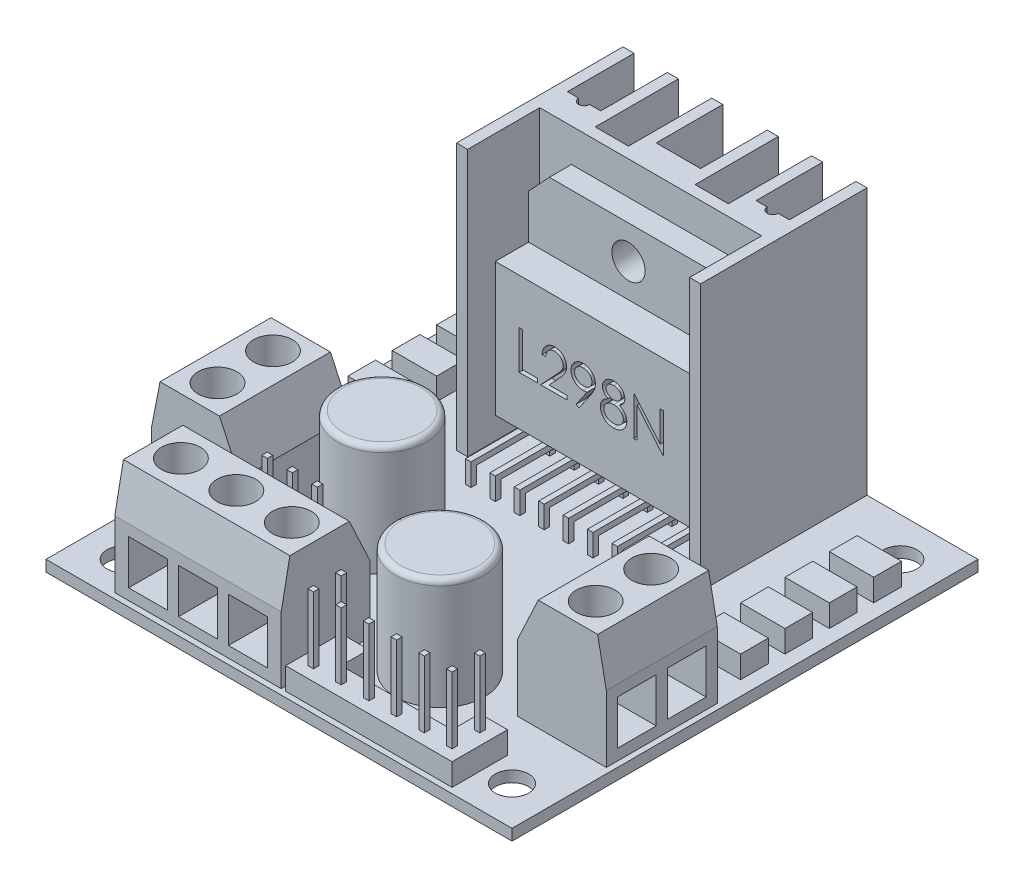
from build123d import *

# Parameters (mm, degrees)
BASE_SKETCH_W             = 42
BASE_SKETCH_H             = 42
BASE_SKETCH_R             = 1.5
BASE_DEPTH                = 1
RADIATOR_DEPTH            = 24
TERMINAL_1_SKETCH_W       = 8
TERMINAL_1_SKETCH_H       = 10
TERMINAL_1_DEPTH          = 10
TERMINAL_2_SKETCH_W       = 15
TERMINAL_2_SKETCH_H       = 8
TERMINAL_2_DEPTH          = 10
CHAMFER_25_SIZE2          = 1.865230633
CHAMFER_25_SIZE           = 4
CHAMFER_10_SIZE           = 4
CHAMFER_10_SIZE2          = 0.777521237
CHAMFER_10_PART_2_SIZE    = 4
CHAMFER_10_PART_2_SIZE2   = 0.777521237
CHAMFER_10_PART_3_SIZE    = 4
CHAMFER_10_PART_3_SIZE2   = 0.777521237
DIODE_SKETCH_W            = 4
DIODE_SKETCH_H            = 2.5
DIODE_DEPTH               = 2
CAPACITOR_SKETCH_R        = 4
CAPACITOR_DEPTH           = 10
FILLET_2_R                = 0.5
RAIL_6_DEPTH              = 2
RAIL_3_SKETCH_W           = 6.6
RAIL_3_SKETCH_H           = 2.2
RAIL_3_DEPTH              = 2
JACK_6_SKETCH_W           = 0.5
JACK_6_SKETCH_H           = 0.5
JACK_6_DEPTH              = 6
JACK_3_SKETCH_W           = 0.5
JACK_3_SKETCH_H           = 0.5
JACK_3_DEPTH              = 6
L298_IC_DEPTH             = 5
L298_CUT_SKETCH_W         = 18
L298_CUT_SKETCH_H         = 6
L298_CUT_DEPTH            = 3
L298_LEG_1_SKETCH_W       = 0.5
L298_LEG_1_SKETCH_H       = 0.5
L298_LEG_1_DEPTH          = 1.5
L298_LEG_2_SKETCH_W       = 0.5
L298_LEG_2_SKETCH_H       = 0.5
L298_LEG_2_DEPTH          = 6
L298_LEG_3_SKETCH_W       = 0.5
L298_LEG_3_SKETCH_H       = 0.5
L298_LEG_3_DEPTH          = 2.5
BOSS_EXTRUDE1_REACH       = 26
SKETCH1_W                 = 0.5
SKETCH1_H                 = 0.5
L298_NAME_DEPTH           = 1
ROLE_SKETCH_R             = 1.5
ROLE_DEPTH                = 11.5
ROLE_TERMINAL_1A_SKETCH_W = 3.5
ROLE_TERMINAL_1A_SKETCH_H = 4
ROLE_TERMINAL_1A_DEPTH    = 4
ROLE_TERMINAL_1B_SKETCH_W = 3.5
ROLE_TERMINAL_1B_SKETCH_H = 4
ROLE_TERMINAL_1B_DEPTH    = 3.5
ROLE_TERMINAL_2_SKETCH_W  = 3.5
ROLE_TERMINAL_2_SKETCH_H  = 4
ROLE_TERMINAL_2_DEPTH     = 3.5
SKETCH4_R                 = 1.75
ROLE_TERMINAL_3_DEPTH     = 3.5


with BuildPart() as part:
    # base_sketch → base (new body)
    with BuildSketch(Plane(origin=(0, 0, 0), x_dir=(1, 0, 0), z_dir=(0, 1, 0))):
        with Locations((-21, -21)):
            Rectangle(BASE_SKETCH_W, BASE_SKETCH_H)
        with Locations((-38.5, -3.5)):
            Circle(BASE_SKETCH_R, mode=Mode.SUBTRACT)
        with Locations((-3.5, -3.5)):
            Circle(BASE_SKETCH_R, mode=Mode.SUBTRACT)
        with Locations((-38.5, -38.5)):
            Circle(BASE_SKETCH_R, mode=Mode.SUBTRACT)
        with Locations((-3.5, -38.5)):
            Circle(BASE_SKETCH_R, mode=Mode.SUBTRACT)
    extrude(amount=BASE_DEPTH)

    # radiator_sketch → radiator (add)
    with BuildSketch(Plane(origin=(0, 1, 0), x_dir=(-1, 0, 0), z_dir=(0, 1, 0))):
        with BuildLine():
            Line((10, 0), (10, 15))
            Line((10, 15), (11, 15))
            Line((11, 15), (11, 8.5))
            Line((11, 8.5), (31, 8.5))
            Line((31, 8.5), (31, 15))
            Line((31, 15), (32, 15))
            Line((32, 15), (32, 0))
            Line((32, 0), (31, 0))
            Line((31, 0), (31, 6))
            Line((31, 6), (30, 6))
            ThreePointArc((30, 6), (29.5, 6.5), (29, 6))
            Line((29, 6), (28, 6))
            Line((28, 6), (28, 0))
            Line((28, 0), (27, 0))
            Line((27, 0), (27, 7.5))
            Line((27, 7.5), (24, 7.5))
            Line((24, 7.5), (24, 0))
            Line((24, 0), (23, 0))
            Line((23, 0), (23, 6))
            Line((23, 6), (19, 6))
            Line((19, 6), (19, 0))
            Line((19, 0), (18, 0))
            Line((18, 0), (18, 7.5))
            Line((18, 7.5), (15, 7.5))
            Line((15, 7.5), (15, 0))
            Line((15, 0), (14, 0))
            Line((14, 0), (14, 6))
            Line((14, 6), (13, 6))
            ThreePointArc((13, 6), (12.5, 6.5), (12, 6))
            Line((12, 6), (11, 6))
            Line((11, 6), (11, 0))
            Line((11, 0), (10, 0))
        make_face()
    extrude(amount=RADIATOR_DEPTH)

    # terminal_1_sketch → terminal_1 (add)
    with BuildSketch(Plane(origin=(0, 1, 0), x_dir=(-1, 0, 0), z_dir=(0, 1, 0))):
        with Locations((4.5, 28)):
            Rectangle(TERMINAL_1_SKETCH_W, TERMINAL_1_SKETCH_H)
        with Locations((37.5, 28)):
            Rectangle(TERMINAL_1_SKETCH_W, TERMINAL_1_SKETCH_H)
    extrude(amount=TERMINAL_1_DEPTH)

    # terminal_2_sketch → terminal_2 (add)
    with BuildSketch(Plane(origin=(0, 1, 0), x_dir=(-1, 0, 0), z_dir=(0, 1, 0))):
        with Locations((28.8, 37.5)):
            Rectangle(TERMINAL_2_SKETCH_W, TERMINAL_2_SKETCH_H)
    extrude(amount=TERMINAL_2_DEPTH)

    # chamfer_25
    chamfer_25_edges = [part.edges().sort_by_distance(p)[0] for p in [
        (-33.5, 11, 28),
        (-8.5, 11, 28),
        (-28.8, 11, 33.5),
    ]]
    chamfer(chamfer_25_edges, length=CHAMFER_25_SIZE, length2=CHAMFER_25_SIZE2)

    # chamfer_10
    chamfer_10_edges = [part.edges().sort_by_distance(p)[0] for p in [
        (-41.5, 11, 28),
    ]]
    chamfer_10_side = [part.faces().sort_by_distance(p)[0] for p in [
        (-41.5, 6, 28),
    ]]
    chamfer(chamfer_10_edges, length=CHAMFER_10_SIZE, length2=CHAMFER_10_SIZE2, reference=chamfer_10_side[0])

    # chamfer_10 part 2
    chamfer_10_part_2_edges = [part.edges().sort_by_distance(p)[0] for p in [
        (-0.5, 11, 28),
    ]]
    chamfer_10_part_2_side = [part.faces().sort_by_distance(p)[0] for p in [
        (-0.5, 6, 28),
    ]]
    chamfer(chamfer_10_part_2_edges, length=CHAMFER_10_PART_2_SIZE, length2=CHAMFER_10_PART_2_SIZE2, reference=chamfer_10_part_2_side[0])

    # chamfer_10 part 3
    chamfer_10_part_3_edges = [part.edges().sort_by_distance(p)[0] for p in [
        (-28.8, 11, 41.5),
    ]]
    chamfer_10_part_3_side = [part.faces().sort_by_distance(p)[0] for p in [
        (-28.8, 6, 41.5),
    ]]
    chamfer(chamfer_10_part_3_edges, length=CHAMFER_10_PART_3_SIZE, length2=CHAMFER_10_PART_3_SIZE2, reference=chamfer_10_part_3_side[0])

    # diode_sketch → diode (add)
    with BuildSketch(Plane(origin=(0, 1, 0), x_dir=(-1, 0, 0), z_dir=(0, 1, 0))):
        with Locations((3.3, 10.85)):
            Rectangle(DIODE_SKETCH_W, DIODE_SKETCH_H)
        with Locations((3.3, 6.85)):
            Rectangle(DIODE_SKETCH_W, DIODE_SKETCH_H)
        with Locations((3.3, 14.85)):
            Rectangle(DIODE_SKETCH_W, DIODE_SKETCH_H)
        with Locations((3.3, 18.85)):
            Rectangle(DIODE_SKETCH_W, DIODE_SKETCH_H)
        with Locations((38.7, 18.85)):
            Rectangle(DIODE_SKETCH_W, DIODE_SKETCH_H)
        with Locations((38.7, 14.85)):
            Rectangle(DIODE_SKETCH_W, DIODE_SKETCH_H)
        with Locations((38.7, 10.85)):
            Rectangle(DIODE_SKETCH_W, DIODE_SKETCH_H)
        with Locations((38.7, 6.85)):
            Rectangle(DIODE_SKETCH_W, DIODE_SKETCH_H)
    extrude(amount=DIODE_DEPTH)

    # capacitor_sketch → capacitor (add)
    with BuildSketch(Plane(origin=(0, 1, 0), x_dir=(-1, 0, 0), z_dir=(0, 1, 0))):
        with Locations((28.5, 25.2)):
            Circle(CAPACITOR_SKETCH_R)
        with Locations((15.5, 33)):
            Circle(CAPACITOR_SKETCH_R)
    extrude(amount=CAPACITOR_DEPTH)

    # fillet 2
    fillet_2_edges = [part.edges().sort_by_distance(p)[0] for p in [
        (-24.5, 11, 25.2),
        (-11.5, 11, 33),
    ]]
    fillet(fillet_2_edges, radius=FILLET_2_R)

    # rail_6_sketch → rail_6 (add)
    with BuildSketch(Plane(origin=(0, 1, 0), x_dir=(-1, 0, 0), z_dir=(0, 1, 0))):
        Polygon((20.9, 41.5), (5.9, 41.5), (5.9, 36.5), (8.4, 36.5), (8.4, 39), (18.4, 39), (18.4, 36.5), (20.9, 36.5), align=None)
    extrude(amount=RAIL_6_DEPTH)

    # rail_3_sketch → rail_3 (add)
    with BuildSketch(Plane(origin=(0, 1, 0), x_dir=(-1, 0, 0), z_dir=(0, 1, 0))):
        with Locations((29.9, 31.9)):
            Rectangle(RAIL_3_SKETCH_W, RAIL_3_SKETCH_H)
    extrude(amount=RAIL_3_DEPTH)

    # jack_6_sketch → jack_6 (add)
    with BuildSketch(Plane(origin=(0, 3, 0), x_dir=(-1, 0, 0), z_dir=(0, 1, 0))):
        with Locations((17.15, 40.25)):
            Rectangle(JACK_6_SKETCH_W, JACK_6_SKETCH_H)
        with Locations((19.65, 40.25)):
            Rectangle(JACK_6_SKETCH_W, JACK_6_SKETCH_H)
        with Locations((14.65, 40.25)):
            Rectangle(JACK_6_SKETCH_W, JACK_6_SKETCH_H)
        with Locations((12.15, 40.25)):
            Rectangle(JACK_6_SKETCH_W, JACK_6_SKETCH_H)
        with Locations((9.65, 40.25)):
            Rectangle(JACK_6_SKETCH_W, JACK_6_SKETCH_H)
        with Locations((7.15, 40.25)):
            Rectangle(JACK_6_SKETCH_W, JACK_6_SKETCH_H)
        with Locations((19.65, 37.75)):
            Rectangle(JACK_6_SKETCH_W, JACK_6_SKETCH_H)
        with Locations((7.15, 37.75)):
            Rectangle(JACK_6_SKETCH_W, JACK_6_SKETCH_H)
    extrude(amount=JACK_6_DEPTH)

    # jack_3_sketch → jack_3 (add)
    with BuildSketch(Plane(origin=(0, 3, 0), x_dir=(1, 0, 0), z_dir=(0, 1, 0))):
        with Locations((-29.9, -31.9)):
            Rectangle(JACK_3_SKETCH_W, JACK_3_SKETCH_H)
        with Locations((-32.15, -31.9)):
            Rectangle(JACK_3_SKETCH_W, JACK_3_SKETCH_H)
        with Locations((-27.65, -31.9)):
            Rectangle(JACK_3_SKETCH_W, JACK_3_SKETCH_H)
    extrude(amount=JACK_3_DEPTH)

    # L298_sketch → L298_IC (add)
    with BuildSketch(Plane.XY.offset(8.5)):
        Polygon((-30, 19.987466442), (-30, 4), (-12, 4), (-12, 19.987466442), (-13.862533558, 22), (-28.137466442, 22), align=None)
    extrude(amount=L298_IC_DEPTH)

    # L298_cut_sketch → L298_cut (cut)
    with BuildSketch(Plane.XY.offset(13.5)):
        with Locations((-21, 19)):
            Rectangle(L298_CUT_SKETCH_W, L298_CUT_SKETCH_H)
    extrude(amount=-L298_CUT_DEPTH, mode=Mode.SUBTRACT)

    # L298_leg_1_sketch → L298_leg_1 (add)
    with BuildSketch(Plane.XZ.offset(-4)):
        with Locations((-27.6, 11)):
            Rectangle(L298_LEG_1_SKETCH_W, L298_LEG_1_SKETCH_H)
        with Locations((-28.7, 11)):
            Rectangle(L298_LEG_1_SKETCH_W, L298_LEG_1_SKETCH_H)
        with Locations((-26.5, 11)):
            Rectangle(L298_LEG_1_SKETCH_W, L298_LEG_1_SKETCH_H)
        with Locations((-25.4, 11)):
            Rectangle(L298_LEG_1_SKETCH_W, L298_LEG_1_SKETCH_H)
        with Locations((-24.3, 11)):
            Rectangle(L298_LEG_1_SKETCH_W, L298_LEG_1_SKETCH_H)
        with Locations((-23.2, 11)):
            Rectangle(L298_LEG_1_SKETCH_W, L298_LEG_1_SKETCH_H)
        with Locations((-22.1, 11)):
            Rectangle(L298_LEG_1_SKETCH_W, L298_LEG_1_SKETCH_H)
        with Locations((-21, 11)):
            Rectangle(L298_LEG_1_SKETCH_W, L298_LEG_1_SKETCH_H)
        with Locations((-19.9, 11)):
            Rectangle(L298_LEG_1_SKETCH_W, L298_LEG_1_SKETCH_H)
        with Locations((-18.8, 11)):
            Rectangle(L298_LEG_1_SKETCH_W, L298_LEG_1_SKETCH_H)
        with Locations((-17.7, 11)):
            Rectangle(L298_LEG_1_SKETCH_W, L298_LEG_1_SKETCH_H)
        with Locations((-16.6, 11)):
            Rectangle(L298_LEG_1_SKETCH_W, L298_LEG_1_SKETCH_H)
        with Locations((-15.5, 11)):
            Rectangle(L298_LEG_1_SKETCH_W, L298_LEG_1_SKETCH_H)
        with Locations((-14.4, 11)):
            Rectangle(L298_LEG_1_SKETCH_W, L298_LEG_1_SKETCH_H)
        with Locations((-13.3, 11)):
            Rectangle(L298_LEG_1_SKETCH_W, L298_LEG_1_SKETCH_H)
    extrude(amount=L298_LEG_1_DEPTH)

    # L298_leg_2_sketch → L298_leg_2 (add)
    with BuildSketch(Plane.XY.offset(11.25)):
        with Locations((-13.3, 2.75)):
            Rectangle(L298_LEG_2_SKETCH_W, L298_LEG_2_SKETCH_H)
        with Locations((-15.5, 2.75)):
            Rectangle(L298_LEG_2_SKETCH_W, L298_LEG_2_SKETCH_H)
        with Locations((-17.7, 2.75)):
            Rectangle(L298_LEG_2_SKETCH_W, L298_LEG_2_SKETCH_H)
        with Locations((-19.9, 2.75)):
            Rectangle(L298_LEG_2_SKETCH_W, L298_LEG_2_SKETCH_H)
        with Locations((-22.1, 2.75)):
            Rectangle(L298_LEG_2_SKETCH_W, L298_LEG_2_SKETCH_H)
        with Locations((-24.3, 2.75)):
            Rectangle(L298_LEG_2_SKETCH_W, L298_LEG_2_SKETCH_H)
        with Locations((-26.5, 2.75)):
            Rectangle(L298_LEG_2_SKETCH_W, L298_LEG_2_SKETCH_H)
        with Locations((-28.7, 2.75)):
            Rectangle(L298_LEG_2_SKETCH_W, L298_LEG_2_SKETCH_H)
    extrude(amount=L298_LEG_2_DEPTH)

    # L298_leg_3_sketch → L298_leg_3 (add)
    with BuildSketch(Plane.XZ):
        with Locations((-28.7, 17)):
            Rectangle(L298_LEG_3_SKETCH_W, L298_LEG_3_SKETCH_H)
        with Locations((-26.5, 17)):
            Rectangle(L298_LEG_3_SKETCH_W, L298_LEG_3_SKETCH_H)
        with Locations((-24.3, 17)):
            Rectangle(L298_LEG_3_SKETCH_W, L298_LEG_3_SKETCH_H)
        with Locations((-22.1, 17)):
            Rectangle(L298_LEG_3_SKETCH_W, L298_LEG_3_SKETCH_H)
        with Locations((-19.9, 17)):
            Rectangle(L298_LEG_3_SKETCH_W, L298_LEG_3_SKETCH_H)
        with Locations((-17.7, 17)):
            Rectangle(L298_LEG_3_SKETCH_W, L298_LEG_3_SKETCH_H)
        with Locations((-15.5, 17)):
            Rectangle(L298_LEG_3_SKETCH_W, L298_LEG_3_SKETCH_H)
        with Locations((-13.3, 17)):
            Rectangle(L298_LEG_3_SKETCH_W, L298_LEG_3_SKETCH_H)
    extrude(amount=-L298_LEG_3_DEPTH)

    # Sketch1 → Boss-Extrude1 (add, up to next)
    with BuildSketch(Plane(origin=(0, 1, 0), x_dir=(1, 0, 0), z_dir=(0, 1, 0)), mode=Mode.PRIVATE) as boss_extrude1_sk1:
        with Locations((-14.4, -11)):
            Rectangle(SKETCH1_W, SKETCH1_H)
    boss_extrude1_tool1 = extrude(boss_extrude1_sk1.sketch, amount=BOSS_EXTRUDE1_REACH, mode=Mode.PRIVATE) - part.part
    add(boss_extrude1_tool1.solids().sort_by_distance((-14.4, 1, 11))[0])
    # Sketch1 → Boss-Extrude1 (add, up to next)
    with BuildSketch(Plane(origin=(0, 1, 0), x_dir=(1, 0, 0), z_dir=(0, 1, 0)), mode=Mode.PRIVATE) as boss_extrude1_sk2:
        with Locations((-16.6, -11)):
            Rectangle(SKETCH1_W, SKETCH1_H)
    boss_extrude1_tool2 = extrude(boss_extrude1_sk2.sketch, amount=BOSS_EXTRUDE1_REACH, mode=Mode.PRIVATE) - part.part
    add(boss_extrude1_tool2.solids().sort_by_distance((-16.6, 1, 11))[0])
    # Sketch1 → Boss-Extrude1 (add, up to next)
    with BuildSketch(Plane(origin=(0, 1, 0), x_dir=(1, 0, 0), z_dir=(0, 1, 0)), mode=Mode.PRIVATE) as boss_extrude1_sk3:
        with Locations((-18.8, -11)):
            Rectangle(SKETCH1_W, SKETCH1_H)
    boss_extrude1_tool3 = extrude(boss_extrude1_sk3.sketch, amount=BOSS_EXTRUDE1_REACH, mode=Mode.PRIVATE) - part.part
    add(boss_extrude1_tool3.solids().sort_by_distance((-18.8, 1, 11))[0])
    # Sketch1 → Boss-Extrude1 (add, up to next)
    with BuildSketch(Plane(origin=(0, 1, 0), x_dir=(1, 0, 0), z_dir=(0, 1, 0)), mode=Mode.PRIVATE) as boss_extrude1_sk4:
        with Locations((-21, -11)):
            Rectangle(SKETCH1_W, SKETCH1_H)
    boss_extrude1_tool4 = extrude(boss_extrude1_sk4.sketch, amount=BOSS_EXTRUDE1_REACH, mode=Mode.PRIVATE) - part.part
    add(boss_extrude1_tool4.solids().sort_by_distance((-21, 1, 11))[0])
    # Sketch1 → Boss-Extrude1 (add, up to next)
    with BuildSketch(Plane(origin=(0, 1, 0), x_dir=(1, 0, 0), z_dir=(0, 1, 0)), mode=Mode.PRIVATE) as boss_extrude1_sk5:
        with Locations((-23.2, -11)):
            Rectangle(SKETCH1_W, SKETCH1_H)
    boss_extrude1_tool5 = extrude(boss_extrude1_sk5.sketch, amount=BOSS_EXTRUDE1_REACH, mode=Mode.PRIVATE) - part.part
    add(boss_extrude1_tool5.solids().sort_by_distance((-23.2, 1, 11))[0])
    # Sketch1 → Boss-Extrude1 (add, up to next)
    with BuildSketch(Plane(origin=(0, 1, 0), x_dir=(1, 0, 0), z_dir=(0, 1, 0)), mode=Mode.PRIVATE) as boss_extrude1_sk6:
        with Locations((-25.4, -11)):
            Rectangle(SKETCH1_W, SKETCH1_H)
    boss_extrude1_tool6 = extrude(boss_extrude1_sk6.sketch, amount=BOSS_EXTRUDE1_REACH, mode=Mode.PRIVATE) - part.part
    add(boss_extrude1_tool6.solids().sort_by_distance((-25.4, 1, 11))[0])
    # Sketch1 → Boss-Extrude1 (add, up to next)
    with BuildSketch(Plane(origin=(0, 1, 0), x_dir=(1, 0, 0), z_dir=(0, 1, 0)), mode=Mode.PRIVATE) as boss_extrude1_sk7:
        with Locations((-27.6, -11)):
            Rectangle(SKETCH1_W, SKETCH1_H)
    boss_extrude1_tool7 = extrude(boss_extrude1_sk7.sketch, amount=BOSS_EXTRUDE1_REACH, mode=Mode.PRIVATE) - part.part
    add(boss_extrude1_tool7.solids().sort_by_distance((-27.6, 1, 11))[0])

    # L298_name_sketch → L298_name (cut)
    with BuildSketch(Plane.XY.offset(13.5)):
        Polygon((-27.846931762, 11.915865738), (-27.532829198, 11.915865738), (-27.532829198, 8.774840097), (-26.186675351, 8.774840097), (-26.186675351, 8.415865738), (-27.846931762, 8.415865738), align=None)
        with BuildLine():
            Line((-25.468726633, 10.838942661), (-25.782829198, 10.838942661))
            add(Edge.make_bspline(
                [(-25.782829198, 10.838942661), (-25.780782045, 10.880613549), (-25.77676149, 10.962454063), (-25.757933201, 11.08177797), (-25.730992324, 11.195832768), (-25.69290087, 11.303702682), (-25.645594592, 11.40634149), (-25.588864565, 11.503341505), (-25.521670714, 11.594332694), (-25.44546398, 11.678471537), (-25.362695341, 11.755659108), (-25.273389402, 11.822314351), (-25.179544374, 11.878632022), (-25.081444976, 11.925713264), (-24.977984412, 11.96105311), (-24.870101554, 11.98727475), (-24.757322418, 12.003051095), (-24.680482396, 12.004746881), (-24.641402915, 12.005609328)],
                knots=[0, 0, 0, 0, 0.000125083, 0.00024566, 0.000361805, 0.000476223, 0.000588214, 0.000700404, 0.000812728, 0.00092691, 0.001040529, 0.001151727, 0.001260545, 0.001368429, 0.001477521, 0.001587884, 0.001701119, 0.00181831, 0.00181831, 0.00181831, 0.00181831], degree=3))
            add(Edge.make_bspline(
                [(-24.641402915, 12.005609328), (-24.603024841, 12.004710871), (-24.527613297, 12.002945436), (-24.417551282, 11.987784407), (-24.312773988, 11.964038815), (-24.213486221, 11.930723399), (-24.120480157, 11.885938972), (-24.033057112, 11.832141433), (-23.950176301, 11.769921602), (-23.875569518, 11.696667788), (-23.807061439, 11.618465404), (-23.747959183, 11.5349775), (-23.69734602, 11.448748214), (-23.65515834, 11.359120013), (-23.624102201, 11.265248985), (-23.600523993, 11.168501782), (-23.587196579, 11.067876971), (-23.585151156, 10.999770415), (-23.584111249, 10.965144584)],
                knots=[0, 0, 0, 0, 0.000115089, 0.000226145, 0.000332614, 0.000437044, 0.000539592, 0.000641561, 0.000744629, 0.00084975, 0.000954621, 0.001056175, 0.001156101, 0.001254284, 0.001352726, 0.001452208, 0.001552655, 0.001656537, 0.001656537, 0.001656537, 0.001656537], degree=3))
            add(Edge.make_bspline(
                [(-23.584111249, 10.965144584), (-23.585804512, 10.916396749), (-23.589161323, 10.819756536), (-23.6178757, 10.677741673), (-23.662722211, 10.540148254), (-23.716719568, 10.429410952), (-23.771192012, 10.340177458), (-23.820279519, 10.266708753), (-23.87774433, 10.187603285), (-23.944422828, 10.103125947), (-24.0189357, 10.012615042), (-24.101957864, 9.916125247), (-24.194081346, 9.814653477), (-24.258739846, 9.745347876), (-24.292244262, 9.709435449)],
                knots=[0, 0, 0, 0, 0.000146118, 0.000289672, 0.0004329, 0.00057934, 0.000657978, 0.000746456, 0.000844345, 0.000951219, 0.001069268, 0.00119604, 0.001333047, 0.001480391, 0.001480391, 0.001480391, 0.001480391], degree=3))
            Line((-24.292244262, 9.709435449), (-25.167945383, 8.774840097))
            Line((-25.167945383, 8.774840097), (-23.539239454, 8.774840097))
            Line((-23.539239454, 8.774840097), (-23.539239454, 8.415865738))
            Line((-23.539239454, 8.415865738), (-25.917444582, 8.415865738))
            Line((-25.917444582, 8.415865738), (-24.560072787, 9.864383366))
            add(Edge.make_bspline(
                [(-24.560072787, 9.864383366), (-24.5270249, 9.898881673), (-24.463546673, 9.965145859), (-24.373764097, 10.061888819), (-24.293125108, 10.15163836), (-24.221107715, 10.234224909), (-24.15927421, 10.310856476), (-24.104401978, 10.37905118), (-24.060436387, 10.44180563), (-24.012720991, 10.514546244), (-23.96650701, 10.603358561), (-23.926794654, 10.711892251), (-23.902579806, 10.823619503), (-23.89967497, 10.89912154), (-23.898213813, 10.937099712)],
                knots=[0, 0, 0, 0, 0.000143319, 0.000275286, 0.00039593, 0.000505287, 0.000603949, 0.000691331, 0.000767782, 0.00083371, 0.000952247, 0.001067137, 0.001179618, 0.001293462, 0.001293462, 0.001293462, 0.001293462], degree=3))
            add(Edge.make_bspline(
                [(-23.898213813, 10.937099712), (-23.898849555, 10.960981111), (-23.900102481, 11.008046761), (-23.911160179, 11.07705252), (-23.927870685, 11.143617334), (-23.951815943, 11.207945953), (-23.983422683, 11.269391605), (-24.021896063, 11.328029085), (-24.066286126, 11.38471805), (-24.117637396, 11.437871349), (-24.174048915, 11.486552554), (-24.233643165, 11.529676639), (-24.296693269, 11.56571575), (-24.362933391, 11.595259247), (-24.432178861, 11.618434629), (-24.504563606, 11.634493208), (-24.579887622, 11.644575692), (-24.631321118, 11.645939864), (-24.657528717, 11.646634969)],
                knots=[0, 0, 0, 0, 7.16e-05, 0.00014111, 0.00020913, 0.00027724, 0.000346538, 0.000415963, 0.000487357, 0.000562233, 0.000637292, 0.000710646, 0.000782564, 0.000854749, 0.000927915, 0.001001225, 0.001076884, 0.001155488, 0.001155488, 0.001155488, 0.001155488], degree=3))
            add(Edge.make_bspline(
                [(-24.657528717, 11.646634969), (-24.68489955, 11.645919936), (-24.738651346, 11.644515731), (-24.817570379, 11.634693067), (-24.892856156, 11.617747227), (-24.964698059, 11.594570552), (-25.033217645, 11.565112004), (-25.098081689, 11.528420259), (-25.159144578, 11.484636766), (-25.216521102, 11.434996209), (-25.269385081, 11.379728608), (-25.315831957, 11.318118645), (-25.356415971, 11.25129123), (-25.391825204, 11.179426679), (-25.420580894, 11.101872899), (-25.442554045, 11.018905194), (-25.459940891, 10.930883813), (-25.465749412, 10.870098728), (-25.468726633, 10.838942661)],
                knots=[0, 0, 0, 0, 8.2106e-05, 0.000161243, 0.000238127, 0.000313291, 0.000387401, 0.000461495, 0.000536397, 0.000612445, 0.000688819, 0.000765383, 0.000843422, 0.000923066, 0.001005373, 0.001091093, 0.001180334, 0.001274175, 0.001274175, 0.001274175, 0.001274175], degree=3))
        make_face()
        with BuildLine():
            Line((-22.462316377, 8.326122148), (-22.71331798, 8.500701475))
            Line((-22.71331798, 8.500701475), (-21.740160928, 9.923277597))
            add(Edge.make_bspline(
                [(-21.740160928, 9.923277597), (-21.802251664, 9.915684534), (-21.924511784, 9.900733369), (-22.047648886, 9.897986714), (-22.108249871, 9.896634969)],
                knots=[0, 0, 0, 0, 0.000187529, 0.000369255, 0.000369255, 0.000369255, 0.000369255], degree=3))
            add(Edge.make_bspline(
                [(-22.108249871, 9.896634969), (-22.144991918, 9.897576045), (-22.217113345, 9.899423296), (-22.323144998, 9.914065104), (-22.425030558, 9.936615232), (-22.522499914, 9.970263987), (-22.615919419, 10.012082196), (-22.705085133, 10.06393921), (-22.789877023, 10.124945501), (-22.869384433, 10.194778493), (-22.941696172, 10.271456545), (-23.00611947, 10.352612188), (-23.059660602, 10.439188159), (-23.104137187, 10.529418378), (-23.137867641, 10.624599729), (-23.162430178, 10.723649129), (-23.177552532, 10.827260771), (-23.179351628, 10.897785902), (-23.180265095, 10.933594103)],
                knots=[0, 0, 0, 0, 0.000110185, 0.000216284, 0.000320547, 0.000422759, 0.000525058, 0.000627155, 0.000731643, 0.000837964, 0.0009441, 0.00104747, 0.001148247, 0.001248901, 0.001348697, 0.001450555, 0.001554666, 0.00166205, 0.00166205, 0.00166205, 0.00166205], degree=3))
            add(Edge.make_bspline(
                [(-23.180265095, 10.933594103), (-23.17853066, 10.982562756), (-23.175126317, 11.078678288), (-23.147727799, 11.219112057), (-23.10266746, 11.3518986), (-23.039839083, 11.476688794), (-22.960704362, 11.591687533), (-22.865595772, 11.695296142), (-22.755091807, 11.786040996), (-22.631709788, 11.864045074), (-22.498356768, 11.926780071), (-22.358688109, 11.973019371), (-22.213773989, 12.000218119), (-22.115606319, 12.00380398), (-22.066182563, 12.005609328)],
                knots=[0, 0, 0, 0, 0.000146818, 0.000288173, 0.000427413, 0.000566316, 0.000705952, 0.000844895, 0.000986821, 0.001133677, 0.001281714, 0.001427825, 0.001574003, 0.00172222, 0.00172222, 0.00172222, 0.00172222], degree=3))
            add(Edge.make_bspline(
                [(-22.066182563, 12.005609328), (-22.017694143, 12.003779165), (-21.921885596, 12.000162935), (-21.78099659, 11.973678966), (-21.646055573, 11.929042293), (-21.517810586, 11.867357729), (-21.399071174, 11.790036822), (-21.292295363, 11.697902298), (-21.199919824, 11.590896771), (-21.122095943, 11.471608281), (-21.059625903, 11.343441299), (-21.01455362, 11.209657377), (-20.986807981, 11.071218656), (-20.983311654, 10.977424181), (-20.981547146, 10.930088494)],
                knots=[0, 0, 0, 0, 0.000145418, 0.000287333, 0.000428343, 0.000570713, 0.000713061, 0.00085223, 0.000992387, 0.001135706, 0.001278381, 0.001418948, 0.001558239, 0.001700158, 0.001700158, 0.001700158, 0.001700158], degree=3))
            add(Edge.make_bspline(
                [(-20.981547146, 10.930088494), (-20.982725555, 10.893344727), (-20.985115663, 10.818819186), (-21.00185197, 10.705588844), (-21.030272155, 10.590137614), (-21.062523854, 10.492416018), (-21.093656022, 10.411707569), (-21.122957153, 10.347955989), (-21.155469307, 10.280854725), (-21.193388072, 10.211107387), (-21.234150369, 10.137824852), (-21.280209646, 10.061742137), (-21.330515217, 9.982757144), (-21.366344937, 9.929510056), (-21.384692178, 9.902243943)],
                knots=[0, 0, 0, 0, 0.000110219, 0.000223552, 0.000342587, 0.000466527, 0.000532018, 0.000601997, 0.000676938, 0.00075567, 0.000840114, 0.000928491, 0.001022434, 0.001121023, 0.001121023, 0.001121023, 0.001121023], degree=3))
            Line((-21.384692178, 9.902243943), (-22.462316377, 8.326122148))
        make_face()
        with BuildLine():
            add(Edge.make_bspline(
                [(-22.050056762, 10.255609328), (-22.022222748, 10.256369711), (-21.968039384, 10.25784992), (-21.888662085, 10.266859162), (-21.813737882, 10.282833148), (-21.743066633, 10.30575286), (-21.675939731, 10.333409529), (-21.613423403, 10.368621515), (-21.555465327, 10.41063815), (-21.5016774, 10.457848166), (-21.453913401, 10.510298749), (-21.41137037, 10.565195856), (-21.375209802, 10.622780466), (-21.346646525, 10.683773728), (-21.32316195, 10.746690937), (-21.306943938, 10.812545292), (-21.297959605, 10.880993693), (-21.29642803, 10.927492351), (-21.29564971, 10.951122148)],
                knots=[0, 0, 0, 0, 8.3507e-05, 0.00016256, 0.000239294, 0.000312908, 0.000385178, 0.000456751, 0.000527578, 0.000599603, 0.000671055, 0.000740051, 0.000807755, 0.000874553, 0.000941763, 0.001008931, 0.001077548, 0.001148448, 0.001148448, 0.001148448, 0.001148448], degree=3))
            add(Edge.make_bspline(
                [(-21.29564971, 10.951122148), (-21.29631938, 10.974761813), (-21.297639045, 11.021346673), (-21.308226344, 11.089896413), (-21.326851568, 11.155589674), (-21.351842052, 11.218786104), (-21.38476229, 11.278966476), (-21.424265776, 11.336886348), (-21.471198226, 11.392178475), (-21.525200792, 11.443542459), (-21.583435345, 11.490890358), (-21.645495845, 11.532676434), (-21.710870761, 11.567697631), (-21.779161251, 11.5965966), (-21.8505096, 11.619148376), (-21.924873588, 11.635365741), (-22.002628994, 11.644337495), (-22.05541028, 11.64585939), (-22.082308364, 11.646634969)],
                knots=[0, 0, 0, 0, 7.09e-05, 0.000139717, 0.000207422, 0.000275384, 0.000343146, 0.000412766, 0.000485392, 0.000560268, 0.000636041, 0.000710323, 0.000784354, 0.000858188, 0.000932471, 0.001008519, 0.001086179, 0.001166885, 0.001166885, 0.001166885, 0.001166885], degree=3))
            add(Edge.make_bspline(
                [(-22.082308364, 11.646634969), (-22.108972518, 11.645858137), (-22.161287367, 11.644334), (-22.238351526, 11.635382794), (-22.312212694, 11.61903931), (-22.383354314, 11.596607046), (-22.451642775, 11.567695475), (-22.517014608, 11.532674599), (-22.579089624, 11.490899977), (-22.637268345, 11.443505204), (-22.691366267, 11.392417558), (-22.737491796, 11.336644129), (-22.777085688, 11.278996605), (-22.809960691, 11.218778097), (-22.834963208, 11.155591811), (-22.85358521, 11.089895834), (-22.864173375, 11.021346824), (-22.865492922, 10.974761864), (-22.866162531, 10.951122148)],
                knots=[0, 0, 0, 0, 8.0005e-05, 0.000156969, 0.000232332, 0.000306614, 0.000380449, 0.000454479, 0.000528762, 0.000604535, 0.000679411, 0.000751586, 0.000821205, 0.000888968, 0.00095693, 0.001024634, 0.001093451, 0.001164351, 0.001164351, 0.001164351, 0.001164351], degree=3))
            add(Edge.make_bspline(
                [(-22.866162531, 10.951122148), (-22.865556605, 10.927473949), (-22.864361608, 10.880835373), (-22.852833818, 10.81230898), (-22.833555538, 10.746620786), (-22.807736147, 10.683132079), (-22.773734557, 10.622460221), (-22.732010709, 10.564892859), (-22.683105163, 10.509777409), (-22.627671676, 10.457970197), (-22.567003515, 10.410418022), (-22.502206769, 10.36888764), (-22.434396932, 10.333815195), (-22.363335301, 10.305673811), (-22.289548501, 10.283062148), (-22.21237337, 10.266888603), (-22.132065132, 10.257936336), (-22.07765515, 10.256392439), (-22.050056762, 10.255609328)],
                knots=[0, 0, 0, 0, 7.09e-05, 0.000139828, 0.000207725, 0.00027595, 0.000345002, 0.000415829, 0.000488844, 0.000565728, 0.000643147, 0.000719775, 0.000796287, 0.0008718, 0.000948761, 0.001027552, 0.001107998, 0.001190805, 0.001190805, 0.001190805, 0.001190805], degree=3))
        make_face(mode=Mode.SUBTRACT)
        with BuildLine():
            add(Edge.make_bspline(
                [(-18.831206601, 10.365685449), (-18.802558054, 10.350747493), (-18.74668382, 10.321613491), (-18.667106611, 10.274702663), (-18.59438161, 10.225261698), (-18.526491048, 10.175625839), (-18.464627698, 10.123894187), (-18.409483285, 10.069861031), (-18.359695665, 10.014875086), (-18.316268881, 9.958005246), (-18.278072044, 9.899402596), (-18.245059909, 9.838913323), (-18.216842706, 9.77666999), (-18.194479767, 9.71199316), (-18.176057976, 9.645832898), (-18.163382371, 9.577334916), (-18.156565453, 9.506950575), (-18.155276639, 9.459382274), (-18.154624069, 9.435296828)],
                knots=[0, 0, 0, 0, 9.692e-05, 0.000189026, 0.000276921, 0.000360637, 0.000441251, 0.000518597, 0.000592078, 0.000663595, 0.000733021, 0.000801734, 0.000870147, 0.000937778, 0.001006834, 0.001076004, 0.001146466, 0.001218736, 0.001218736, 0.001218736, 0.001218736], degree=3))
            add(Edge.make_bspline(
                [(-18.154624069, 9.435296828), (-18.15539549, 9.401599095), (-18.156922421, 9.334898638), (-18.170222405, 9.236452527), (-18.190135383, 9.140840745), (-18.219214895, 9.048084254), (-18.256928286, 8.958694881), (-18.303405122, 8.872596107), (-18.356016327, 8.788376798), (-18.398268567, 8.736557396), (-18.419648108, 8.710336892)],
                knots=[0, 0, 0, 0, 0.000101049, 0.000200014, 0.00029751, 0.000393751, 0.000491154, 0.000588073, 0.000687071, 0.000788472, 0.000788472, 0.000788472, 0.000788472], degree=3))
            add(Edge.make_bspline(
                [(-18.419648108, 8.710336892), (-18.447484582, 8.679743118), (-18.502813548, 8.618933625), (-18.597596475, 8.539982815), (-18.701618359, 8.473633421), (-18.814476692, 8.419561526), (-18.935869793, 8.377475667), (-19.065771798, 8.347233149), (-19.204435951, 8.32991072), (-19.299741422, 8.327406731), (-19.348634486, 8.326122148)],
                knots=[0, 0, 0, 0, 0.000123978, 0.000246423, 0.000368759, 0.000493253, 0.000620972, 0.000753455, 0.000892683, 0.001039354, 0.001039354, 0.001039354, 0.001039354], degree=3))
            add(Edge.make_bspline(
                [(-19.348634486, 8.326122148), (-19.395647875, 8.327274626), (-19.487131154, 8.329517231), (-19.620289031, 8.344711663), (-19.744412101, 8.371339529), (-19.860222069, 8.407784139), (-19.967020763, 8.455194367), (-20.064503864, 8.514202776), (-20.154077836, 8.582434218), (-20.23302431, 8.661848296), (-20.303112753, 8.746906168), (-20.364680807, 8.834657778), (-20.415854885, 8.925111136), (-20.45918198, 9.016917503), (-20.492350003, 9.111363657), (-20.515322213, 9.20796367), (-20.529911527, 9.306548813), (-20.531852662, 9.373080466), (-20.532829198, 9.406550834)],
                knots=[0, 0, 0, 0, 0.000141037, 0.000274444, 0.00040137, 0.000521327, 0.000638076, 0.000750983, 0.00086247, 0.000975011, 0.001086056, 0.001192834, 0.001296147, 0.001397463, 0.001497025, 0.001595826, 0.001694979, 0.00179536, 0.00179536, 0.00179536, 0.00179536], degree=3))
            add(Edge.make_bspline(
                [(-20.532829198, 9.406550834), (-20.532251316, 9.431110026), (-20.53110922, 9.479647658), (-20.523204371, 9.551356986), (-20.51049591, 9.621153121), (-20.493236453, 9.689293865), (-20.469845427, 9.755283137), (-20.441603294, 9.819433611), (-20.408671341, 9.88181771), (-20.370590176, 9.942776591), (-20.326288152, 10.001456103), (-20.276124502, 10.058852098), (-20.219096634, 10.114073965), (-20.155838975, 10.16779639), (-20.087074435, 10.220972364), (-20.011016905, 10.270728092), (-19.929682637, 10.320586057), (-19.871877231, 10.350394382), (-19.84222423, 10.365685449)],
                knots=[0, 0, 0, 0, 7.3671e-05, 0.0001456, 0.000216149, 0.000286381, 0.000356229, 0.000425923, 0.00049649, 0.000567687, 0.000641305, 0.000716824, 0.000796154, 0.000879197, 0.00096572, 0.001056725, 0.001151716, 0.001251771, 0.001251771, 0.001251771, 0.001251771], degree=3))
            add(Edge.make_bspline(
                [(-19.84222423, 10.365685449), (-19.882815604, 10.387820218), (-19.961411867, 10.430679326), (-20.065481308, 10.509426132), (-20.154871932, 10.594713947), (-20.227126649, 10.688343741), (-20.283998877, 10.787390616), (-20.323017482, 10.891234868), (-20.349413966, 10.997950982), (-20.352028793, 11.070857178), (-20.353342018, 11.107472308)],
                knots=[0, 0, 0, 0, 0.000138535, 0.000268243, 0.000390218, 0.00050816, 0.000621822, 0.000731457, 0.000840134, 0.00094978, 0.00094978, 0.00094978, 0.00094978], degree=3))
            add(Edge.make_bspline(
                [(-20.353342018, 11.107472308), (-20.351706594, 11.144769867), (-20.348419106, 11.219744464), (-20.321835786, 11.331350587), (-20.278515719, 11.440967152), (-20.219594722, 11.548062865), (-20.146207506, 11.64901308), (-20.05816096, 11.739554026), (-19.957557663, 11.818865508), (-19.844899796, 11.885441681), (-19.723663561, 11.93962534), (-19.595747837, 11.977003763), (-19.463381344, 12.001439879), (-19.373283624, 12.004206534), (-19.327600832, 12.005609328)],
                knots=[0, 0, 0, 0, 0.000111795, 0.000224728, 0.000342168, 0.000464543, 0.000590474, 0.000715423, 0.000842224, 0.000973648, 0.001107055, 0.001239485, 0.001372621, 0.001509557, 0.001509557, 0.001509557, 0.001509557], degree=3))
            add(Edge.make_bspline(
                [(-19.327600832, 12.005609328), (-19.283097017, 12.004162985), (-19.195340564, 12.001310961), (-19.066345936, 11.977524083), (-18.942921059, 11.937794563), (-18.82549156, 11.88389734), (-18.716159693, 11.817510399), (-18.619557383, 11.737109525), (-18.534224801, 11.646967974), (-18.463640407, 11.546048371), (-18.405477518, 11.439364177), (-18.364976617, 11.327741656), (-18.339024643, 11.213592597), (-18.335751278, 11.136354593), (-18.334111249, 11.097656603)],
                knots=[0, 0, 0, 0, 0.000133436, 0.000263121, 0.000391946, 0.000521517, 0.000649943, 0.000774455, 0.000897469, 0.001021193, 0.0011429, 0.001260905, 0.001376422, 0.001492413, 0.001492413, 0.001492413, 0.001492413], degree=3))
            add(Edge.make_bspline(
                [(-18.334111249, 11.097656603), (-18.335545809, 11.059679939), (-18.338363205, 10.98509593), (-18.362063145, 10.87636941), (-18.401976458, 10.774547371), (-18.456470621, 10.678474419), (-18.527496109, 10.589892921), (-18.614104842, 10.507676451), (-18.71560632, 10.431149623), (-18.791867206, 10.387963258), (-18.831206601, 10.365685449)],
                knots=[0, 0, 0, 0, 0.000113843, 0.000223582, 0.000331909, 0.000440874, 0.000553657, 0.00067118, 0.000798364, 0.000933876, 0.000933876, 0.000933876, 0.000933876], degree=3))
        make_face()
        with BuildLine():
            add(Edge.make_bspline(
                [(-19.345128877, 11.646634969), (-19.369679683, 11.645983528), (-19.417711794, 11.644709026), (-19.488140465, 11.638050389), (-19.555112832, 11.625097172), (-19.619328633, 11.60785846), (-19.679907445, 11.584570472), (-19.737672, 11.557175463), (-19.79163919, 11.523869397), (-19.842460493, 11.486508199), (-19.888211267, 11.445415293), (-19.928815819, 11.402601575), (-19.962543933, 11.357226182), (-19.991185043, 11.310417823), (-20.01196656, 11.260787247), (-20.027530864, 11.20985607), (-20.038052255, 11.156980686), (-20.038840645, 11.120844176), (-20.039239454, 11.102564456)],
                knots=[0, 0, 0, 0, 7.3671e-05, 0.000144133, 0.000211925, 0.000278091, 0.000343329, 0.00040636, 0.000469609, 0.000533272, 0.00059534, 0.000653874, 0.000709964, 0.000764674, 0.00081807, 0.000870854, 0.000924347, 0.000979106, 0.000979106, 0.000979106, 0.000979106], degree=3))
            add(Edge.make_bspline(
                [(-20.039239454, 11.102564456), (-20.038552087, 11.084283946), (-20.037193751, 11.048159033), (-20.026688623, 10.994813167), (-20.011031768, 10.942391531), (-19.986381107, 10.89214062), (-19.956814749, 10.84231726), (-19.920323273, 10.794166674), (-19.876834245, 10.74752129), (-19.827806804, 10.702777848), (-19.774395267, 10.660879085), (-19.717811223, 10.624505904), (-19.658764832, 10.594071793), (-19.597862763, 10.568742388), (-19.534484315, 10.549052451), (-19.469017842, 10.535083805), (-19.40145234, 10.526401808), (-19.355671759, 10.525364787), (-19.332508685, 10.524840097)],
                knots=[0, 0, 0, 0, 5.48e-05, 0.000108292, 0.000162623, 0.00021845, 0.000275685, 0.000336262, 0.000399273, 0.000466763, 0.000535204, 0.00060269, 0.000668229, 0.000734243, 0.000800327, 0.000867022, 0.000934854, 0.001004321, 0.001004321, 0.001004321, 0.001004321], degree=3))
            add(Edge.make_bspline(
                [(-19.332508685, 10.524840097), (-19.302758581, 10.525712964), (-19.243552213, 10.527450077), (-19.156272882, 10.543601251), (-19.071410237, 10.569007168), (-18.989871333, 10.603767135), (-18.913766748, 10.647394995), (-18.845926679, 10.699628013), (-18.786929787, 10.75926011), (-18.737389176, 10.825362946), (-18.69897933, 10.895714534), (-18.669077522, 10.966314827), (-18.651616307, 11.037917058), (-18.64933874, 11.085884022), (-18.648213813, 11.109575674)],
                knots=[0, 0, 0, 0, 8.9178e-05, 0.000177474, 0.000265314, 0.000354521, 0.00044279, 0.000527774, 0.000610569, 0.000693722, 0.000774691, 0.000850468, 0.000923253, 0.000994288, 0.000994288, 0.000994288, 0.000994288], degree=3))
            add(Edge.make_bspline(
                [(-18.648213813, 11.109575674), (-18.64874571, 11.12620371), (-18.649801451, 11.159207978), (-18.658501507, 11.207946343), (-18.67287734, 11.255575927), (-18.69234042, 11.302490197), (-18.717950215, 11.348030929), (-18.748314402, 11.392914017), (-18.785198904, 11.436129781), (-18.826595337, 11.47868533), (-18.873540746, 11.518069353), (-18.925944658, 11.552704064), (-18.983538408, 11.58211642), (-19.046323358, 11.606005175), (-19.114068282, 11.623947525), (-19.186461157, 11.637383872), (-19.264105604, 11.644956984), (-19.317535355, 11.646063509), (-19.345128877, 11.646634969)],
                knots=[0, 0, 0, 0, 4.9859e-05, 9.8962e-05, 0.000147986, 0.000198898, 0.000250994, 0.000304472, 0.000361207, 0.000421197, 0.00048242, 0.000544646, 0.00060924, 0.000676039, 0.000745771, 0.000819205, 0.000896713, 0.000979493, 0.000979493, 0.000979493, 0.000979493], degree=3))
        make_face(mode=Mode.SUBTRACT)
        with BuildLine():
            add(Edge.make_bspline(
                [(-19.324796345, 10.165865738), (-19.355922131, 10.165312097), (-19.416983327, 10.164225987), (-19.506440255, 10.152136487), (-19.592293421, 10.135307094), (-19.674253357, 10.109776255), (-19.752285454, 10.076579765), (-19.826812136, 10.036645225), (-19.897263266, 9.989439782), (-19.962665992, 9.935563166), (-20.022389322, 9.877503712), (-20.074787622, 9.816041577), (-20.119285142, 9.752319044), (-20.155118393, 9.685526815), (-20.184530125, 9.617079204), (-20.203844002, 9.545271609), (-20.216225714, 9.471484496), (-20.217888346, 9.421324397), (-20.218726633, 9.396034007)],
                knots=[0, 0, 0, 0, 9.3315e-05, 0.000183061, 0.000270376, 0.000355532, 0.000440046, 0.000524429, 0.000608823, 0.000694017, 0.000778303, 0.000858382, 0.000935982, 0.001010962, 0.001085443, 0.001158927, 0.001233504, 0.001309342, 0.001309342, 0.001309342, 0.001309342], degree=3))
            add(Edge.make_bspline(
                [(-20.218726633, 9.396034007), (-20.217363375, 9.364603101), (-20.214658701, 9.302244918), (-20.193202062, 9.210081846), (-20.158766527, 9.120860792), (-20.110741311, 9.035308839), (-20.051273738, 8.955358732), (-19.97814727, 8.885669957), (-19.895906433, 8.823748478), (-19.801768579, 8.773667945), (-19.698940112, 8.73367309), (-19.587448384, 8.706117127), (-19.468893465, 8.687875677), (-19.387033873, 8.686037496), (-19.345128877, 8.685096507)],
                knots=[0, 0, 0, 0, 9.4212e-05, 0.000186914, 0.000282354, 0.00038028, 0.000480401, 0.000580061, 0.000682286, 0.000788322, 0.000898864, 0.001012456, 0.001132235, 0.001257861, 0.001257861, 0.001257861, 0.001257861], degree=3))
            add(Edge.make_bspline(
                [(-19.345128877, 8.685096507), (-19.312378509, 8.685725316), (-19.24857029, 8.686950436), (-19.155484341, 8.69776473), (-19.067639793, 8.714914355), (-18.985206994, 8.739857901), (-18.907263154, 8.770307877), (-18.8351298, 8.809479959), (-18.766951273, 8.854032282), (-18.706087151, 8.906890438), (-18.650653942, 8.963369933), (-18.602320649, 9.023159976), (-18.560363098, 9.084635609), (-18.527432142, 9.149186093), (-18.501105889, 9.215573008), (-18.482182334, 9.284408519), (-18.470506119, 9.355903752), (-18.469325223, 9.404402823), (-18.468726633, 9.428986731)],
                knots=[0, 0, 0, 0, 9.822e-05, 0.000191363, 0.000280739, 0.000366362, 0.000449427, 0.000531293, 0.000612187, 0.000693253, 0.000772583, 0.000849342, 0.000923624, 0.000995434, 0.001066261, 0.001137531, 0.001209227, 0.001282928, 0.001282928, 0.001282928, 0.001282928], degree=3))
            add(Edge.make_bspline(
                [(-18.468726633, 9.428986731), (-18.469632482, 9.452864072), (-18.471418657, 9.499946017), (-18.482755348, 9.569712543), (-18.502671226, 9.637115358), (-18.529998622, 9.702965364), (-18.566379585, 9.765928314), (-18.609224455, 9.827644486), (-18.660918574, 9.88640093), (-18.71933117, 9.942654026), (-18.782990131, 9.994669763), (-18.850657275, 10.040684202), (-18.921811737, 10.079436318), (-18.996302948, 10.110952813), (-19.073965504, 10.135740283), (-19.154742283, 10.153056278), (-19.238727858, 10.163955881), (-19.295782728, 10.165221927), (-19.324796345, 10.165865738)],
                knots=[0, 0, 0, 0, 7.1638e-05, 0.000141258, 0.00021137, 0.000282076, 0.000354604, 0.000429101, 0.000507127, 0.000588942, 0.000672164, 0.000753448, 0.00083408, 0.000914819, 0.000995752, 0.001078265, 0.001162358, 0.001249368, 0.001249368, 0.001249368, 0.001249368], degree=3))
        make_face(mode=Mode.SUBTRACT)
        Polygon((-17.526418941, 8.415865738), (-17.526418941, 11.915865738), (-17.460513492, 11.915865738), (-15.148213813, 9.161158206), (-15.148213813, 11.915865738), (-14.834111249, 11.915865738), (-14.834111249, 8.415865738), (-14.905625672, 8.415865738), (-17.212316377, 11.164263174), (-17.212316377, 8.415865738), align=None)
    extrude(amount=-L298_NAME_DEPTH, mode=Mode.SUBTRACT)

    # role_sketch → role (cut, through all)
    with BuildSketch(Plane.XY.offset(10.5)):
        with Locations((-21, 19)):
            Circle(ROLE_SKETCH_R)
    extrude(amount=-ROLE_DEPTH, mode=Mode.SUBTRACT)

    # role_terminal_1a_sketch → role_terminal_1a (cut)
    with BuildSketch(Plane(origin=(0, 0, 0), x_dir=(0, 0, -1), z_dir=(1, 0, 0))):
        with Locations((-30.25, 4)):
            Rectangle(ROLE_TERMINAL_1A_SKETCH_W, ROLE_TERMINAL_1A_SKETCH_H)
        with Locations((-25.75, 4)):
            Rectangle(ROLE_TERMINAL_1A_SKETCH_W, ROLE_TERMINAL_1A_SKETCH_H)
    extrude(amount=-ROLE_TERMINAL_1A_DEPTH, mode=Mode.SUBTRACT)

    # role_terminal_1b_sketch → role_terminal_1b (cut)
    with BuildSketch(Plane.ZY.offset(41.5)):
        with Locations((25.75, 4)):
            Rectangle(ROLE_TERMINAL_1B_SKETCH_W, ROLE_TERMINAL_1B_SKETCH_H)
        with Locations((30.25, 4)):
            Rectangle(ROLE_TERMINAL_1B_SKETCH_W, ROLE_TERMINAL_1B_SKETCH_H)
    extrude(amount=-ROLE_TERMINAL_1B_DEPTH, mode=Mode.SUBTRACT)

    # role_terminal_2_sketch → role_terminal_2 (cut)
    with BuildSketch(Plane.XY.offset(41.5)):
        with Locations((-33.3, 4)):
            Rectangle(ROLE_TERMINAL_2_SKETCH_W, ROLE_TERMINAL_2_SKETCH_H)
        with Locations((-28.8, 4)):
            Rectangle(ROLE_TERMINAL_2_SKETCH_W, ROLE_TERMINAL_2_SKETCH_H)
        with Locations((-24.3, 4)):
            Rectangle(ROLE_TERMINAL_2_SKETCH_W, ROLE_TERMINAL_2_SKETCH_H)
    extrude(amount=-ROLE_TERMINAL_2_DEPTH, mode=Mode.SUBTRACT)

    # Sketch4 → role_terminal_3 (cut)
    with BuildSketch(Plane(origin=(0, 11, 0), x_dir=(1, 0, 0), z_dir=(0, 1, 0))):
        with Locations((-38.043854698, -25.5)):
            Circle(SKETCH4_R)
        with Locations((-38.043854698, -30.5)):
            Circle(SKETCH4_R)
        with Locations((-28.8, -38.043854698)):
            Circle(SKETCH4_R)
        with Locations((-33.8, -38.043854698)):
            Circle(SKETCH4_R)
        with Locations((-23.8, -38.043854698)):
            Circle(SKETCH4_R)
        with Locations((-3.956145302, -30.5)):
            Circle(SKETCH4_R)
        with Locations((-3.956145302, -25.5)):
            Circle(SKETCH4_R)
    extrude(amount=-ROLE_TERMINAL_3_DEPTH, mode=Mode.SUBTRACT)


solid = part.part
